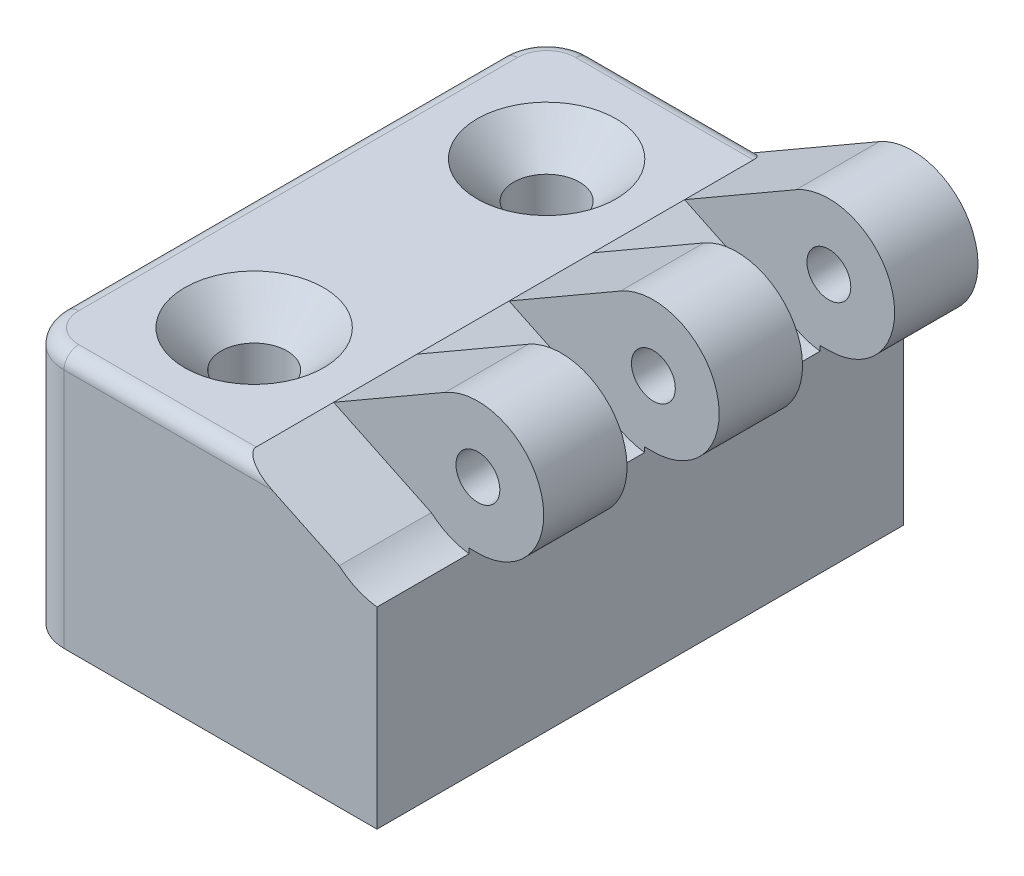
from build123d import *

# Parameters (mm, degrees)
CROQUIS1_R              = 1.5
SALIENTE_EXTRUIR1_DEPTH = 36
CORTAR_EXTRUIR1_DEPTH   = 6.3
MATRIZL1_COUNT          = 3
MATRIZL1_PITCH          = 12
CROQUIS3_R              = 2.25
CORTAR_EXTRUIR2_DEPTH   = 8.5
CHAFL_N1_SIZE           = 2.5
REDONDEO1_R             = 3
REDONDEO2_R             = 1
SKETCH1_R               = 2.25
BOSS_EXTRUDE2_DEPTH     = 10


with BuildPart() as part:
    # Croquis1 → Saliente-Extruir1 (new body)
    with BuildSketch(Plane.XY):
        with BuildLine():
            Line((12.75, 7.897114317), (5.133974596, 3.5))
            Line((5.133974596, 3.5), (-10, 3.5))
            Line((-10, 3.5), (-10, -4))
            Line((-10, -4), (14.4, -4))
            Line((14.4, -4), (14.4, -0.5))
            Line((14.4, -0.5), (15, -0.5))
            ThreePointArc((15, -0.5), (19.346666218, 5.164685703), (12.75, 7.897114317))
        make_face()
        with Locations((15, 4)):
            Circle(CROQUIS1_R, mode=Mode.SUBTRACT)
    extrude(amount=-SALIENTE_EXTRUIR1_DEPTH)

    # Croquis2 → Cortar-Extruir1 (cut)
    with BuildSketch(Plane.XY):
        with BuildLine():
            Line((14.4, -0.842600764), (15, -0.5))
            ThreePointArc((15, -0.5), (19.346666218, 5.164685703), (12.75, 7.897114317))
            Line((12.75, 7.897114317), (5.133974596, 3.5))
            Line((5.133974596, 3.5), (11.80761005, 0.309549003))
            ThreePointArc((11.80761005, 0.309549003), (13.018228657, -0.459076642), (14.4, -0.842600764))
        make_face()
    cortar_extruir1 = extrude(amount=-CORTAR_EXTRUIR1_DEPTH, mode=Mode.SUBTRACT)

    # MatrizL1: Cortar-Extruir1 ×3
    with Locations(*[(0, 0, -i * MATRIZL1_PITCH) for i in range(1, MATRIZL1_COUNT)]):
        add(cortar_extruir1, mode=Mode.SUBTRACT)

    # Croquis3 → Cortar-Extruir2 (cut, through all)
    with BuildSketch(Plane(origin=(0, 3.5, 0), x_dir=(1, 0, 0), z_dir=(0, 1, 0))):
        with Locations((-2, 28)):
            Circle(CROQUIS3_R)
        with Locations((-2, 8)):
            Circle(CROQUIS3_R)
    extrude(amount=-CORTAR_EXTRUIR2_DEPTH, mode=Mode.SUBTRACT)

    # Chaflán1
    chafl_n1_edges = [part.edges().sort_by_distance(p)[0] for p in [
        (-4.25, 3.5, -28),
        (-4.25, 3.5, -8),
    ]]
    chamfer(chafl_n1_edges, length=CHAFL_N1_SIZE)

    # Redondeo1
    redondeo1_edges = [part.edges().sort_by_distance(p)[0] for p in [
        (-10, -0.25, -36),
        (-10, -0.25, 0),
    ]]
    fillet(redondeo1_edges, radius=REDONDEO1_R)

    # Redondeo2
    redondeo2_edges = [part.edges().sort_by_distance(p)[0] for p in [
        (-10, 3.5, -18),
        (-9.121320344, 3.5, -0.878679656),
        (-9.121320344, 3.5, -35.121320344),
        (-0.933012702, 3.5, -36),
        (-0.933012702, 3.5, 0),
    ]]
    fillet(redondeo2_edges, radius=REDONDEO2_R)

    # Sketch1 → Boss-Extrude2 (add)
    with BuildSketch(Plane.XZ.offset(4)):
        with BuildLine():
            Line((-10, -3), (-10, -33))
            ThreePointArc((-10, -33), (-9.121320344, -35.121320344), (-7, -36))
            Line((-7, -36), (14.4, -36))
            Line((14.4, -36), (14.4, 0))
            Line((14.4, 0), (-7, 0))
            ThreePointArc((-7, 0), (-9.121320344, -0.878679656), (-10, -3))
        make_face()
        with Locations((-2, -8)):
            Circle(SKETCH1_R, mode=Mode.SUBTRACT)
        with Locations((-2, -28)):
            Circle(SKETCH1_R, mode=Mode.SUBTRACT)
    extrude(amount=BOSS_EXTRUDE2_DEPTH)


solid = part.part
